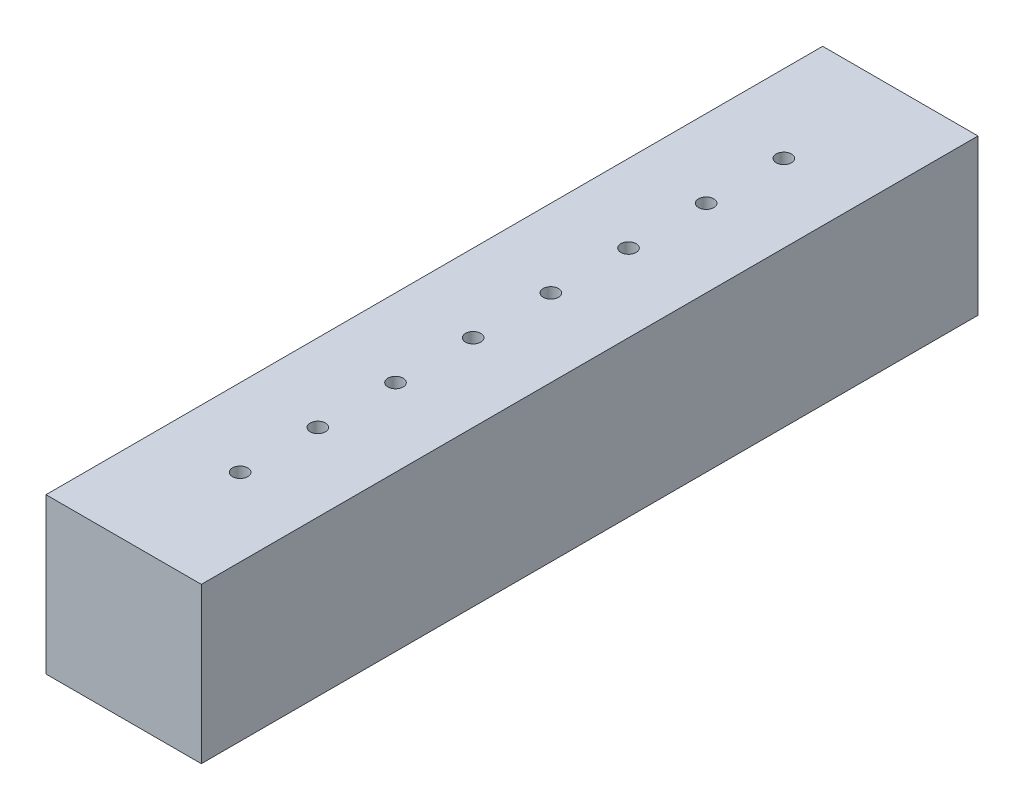
from build123d import *

# Parameters (mm, degrees)
SKETCH1_W           = 50.8
SKETCH1_H           = 254
BOSS_EXTRUDE1_DEPTH = 50.8
SKETCH3_R           = 2.5019
CUT_EXTRUDE1_DEPTH  = 8.89


with BuildPart() as part:
    # Sketch1 → Boss-Extrude1 (new body)
    with BuildSketch(Plane(origin=(0, 0, 0), x_dir=(1, 0, 0), z_dir=(0, 1, 0))):
        Rectangle(SKETCH1_W, SKETCH1_H)
    extrude(amount=BOSS_EXTRUDE1_DEPTH)

    # Sketch3 → Cut-Extrude1 (cut)
    with BuildSketch(Plane(origin=(0, 50.8, 0), x_dir=(1, 0, 0), z_dir=(0, 1, 0))):
        with Locations((0, 88.9)):
            Circle(SKETCH3_R)
        with Locations((0, 63.5)):
            Circle(SKETCH3_R)
        with Locations((0, 38.1)):
            Circle(SKETCH3_R)
        with Locations((0, 12.7)):
            Circle(SKETCH3_R)
        with Locations((0, -12.7)):
            Circle(SKETCH3_R)
        with Locations((0, -38.1)):
            Circle(SKETCH3_R)
        with Locations((0, -63.5)):
            Circle(SKETCH3_R)
        with Locations((0, -88.9)):
            Circle(SKETCH3_R)
    extrude(amount=-CUT_EXTRUDE1_DEPTH, mode=Mode.SUBTRACT)


solid = part.part
